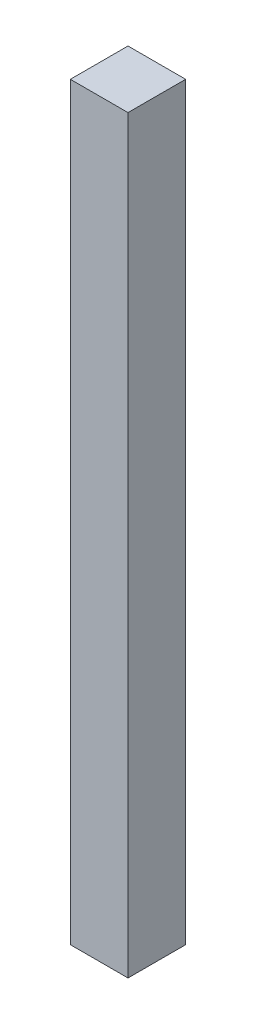
from build123d import *

# Parameters (mm, degrees)
ESQUISSE1_W        = 20
ESQUISSE1_H        = 20
BOSS_EXTRU_1_DEPTH = 260


with BuildPart() as part:
    # Esquisse1 → Boss.-Extru.1 (new body)
    with BuildSketch(Plane(origin=(0, 0, 0), x_dir=(1, 0, 0), z_dir=(0, 1, 0))):
        with Locations((-10, 10)):
            Rectangle(ESQUISSE1_W, ESQUISSE1_H)
    extrude(amount=BOSS_EXTRU_1_DEPTH)


solid = part.part
